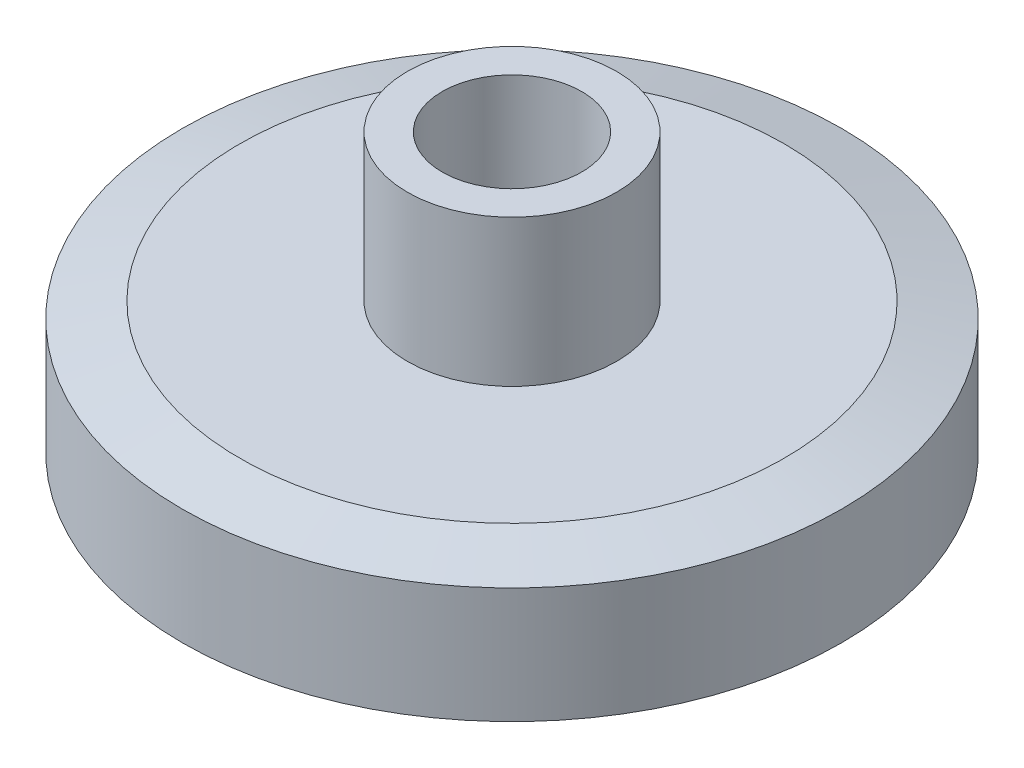
from build123d import *

# Parameters (mm, degrees)
CHAMFER_2_SIZE           = 1.645
CHAMFER_2_SIZE2          = 0.440776422
CHAMFER_3_SIZE           = 1.645
CHAMFER_3_SIZE2          = 0.440776422
SKETCH_4_R               = 2
CUT_EXTRUDE_2_DEPTH      = 1
CUT_EXTRUDE_2_DEPTH_BACK = 9.4


with BuildPart() as part:
    # Эскиз2 → Повернуть2 (revolve)
    with BuildSketch(Plane.XY):
        Polygon((0, 0), (9.45, 0), (9.45, 4.2), (3, 4.2), (3, 8.4), (0, 8.4), align=None)
    revolve(axis=Axis((0, 8.4, 0), (0, -1, 0)))

    # Фаска2
    chamfer_2_edges = [part.edges().sort_by_distance(p)[0] for p in [
        (-9.45, 4.2, 0),
    ]]
    chamfer_2_side = [part.faces().sort_by_distance(p)[0] for p in [
        (-9.182713637, 4.2, 0),
    ]]
    chamfer(chamfer_2_edges, length=CHAMFER_2_SIZE, length2=CHAMFER_2_SIZE2, reference=chamfer_2_side[0])

    # Фаска3
    chamfer_3_edges = [part.edges().sort_by_distance(p)[0] for p in [
        (-9.45, 0, 0),
    ]]
    chamfer_3_side = [part.faces().sort_by_distance(p)[0] for p in [
        (0, 0, 0),
    ]]
    chamfer(chamfer_3_edges, length=CHAMFER_3_SIZE, length2=CHAMFER_3_SIZE2, reference=chamfer_3_side[0])

    # Эскиз4 → Вырез-Вытянуть2 (cut, two sides)
    with BuildSketch(Plane(origin=(0, 8.4, 0), x_dir=(1, 0, 0), z_dir=(0, 1, 0))) as cut_extrude_2_sk:
        Circle(SKETCH_4_R)
    extrude(amount=CUT_EXTRUDE_2_DEPTH, mode=Mode.SUBTRACT)
    extrude(cut_extrude_2_sk.sketch, amount=-CUT_EXTRUDE_2_DEPTH_BACK, mode=Mode.SUBTRACT)


solid = part.part
